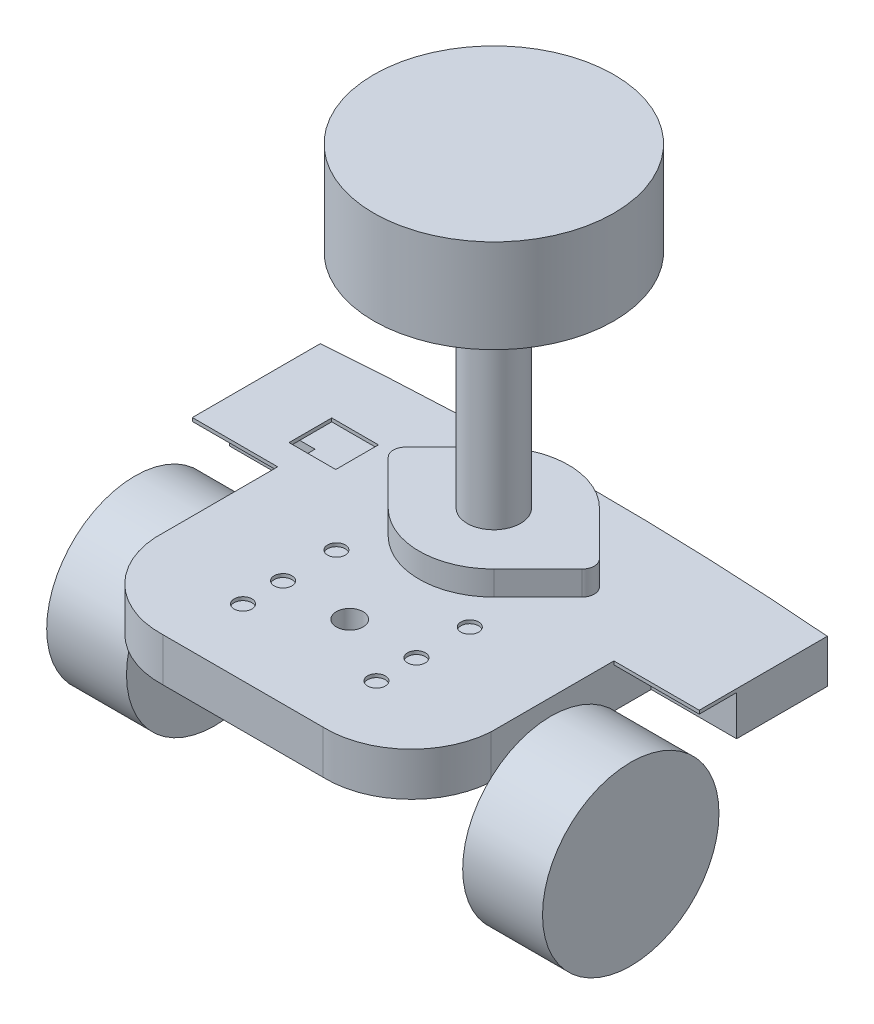
from build123d import *

# Parameters (mm, degrees)
EXTRUDE1_DEPTH     = 0.8128
SKETCH3_R          = 17.78
SKETCH3_R_2        = 1.651
EXTRUDE2_DEPTH     = 1.8128
SKETCH4_W          = 11.1125
SKETCH4_H          = 10.16
CUT_EXTRUDE1_DEPTH = 1.8128
SKETCH5_R          = 2.1082
EXTRUDE3_DEPTH     = 1.8128
EXTRUDE5_DEPTH     = 0.8128
EXTRUDE6_DEPTH     = 9.525
SKETCH8_R          = 2.918849546
SKETCH8_R_2        = 17.78
EXTRUDE7_DEPTH     = 6.604
SKETCH9_R          = 21
EXTRUDE8_DEPTH     = 19
SKETCH10_R         = 6.35
EXTRUDE9_DEPTH     = 52.832
SKETCH11_R         = 28.575
EXTRUDE10_DEPTH    = 22.225
SKETCH12_R         = 3.175
EXTRUDE11_DEPTH    = 46.892


with BuildPart() as part:
    # Sketch1 → Extrude1 (new body)
    with BuildSketch(Plane(origin=(0, 0, 0), x_dir=(1, 0, 0), z_dir=(0, 1, 0))):
        with BuildLine():
            Line((19.05, 0), (-19.05, 0))
            ThreePointArc((-19.05, 0), (-33.392740352, 5.273235613), (-40.005, 19.05))
            Line((-40.005, 19.05), (-40.005, 48.26))
            Line((-40.005, 48.26), (-60.325, 48.26))
            Line((-60.325, 48.26), (-60.325, 78.74))
            Line((-60.325, 78.74), (60.325, 78.74))
            Line((60.325, 78.74), (60.325, 48.26))
            Line((60.325, 48.26), (40.005, 48.26))
            Line((40.005, 48.26), (40.005, 19.05))
            ThreePointArc((40.005, 19.05), (33.392740352, 5.273235613), (19.05, 0))
        make_face()
    extrude(amount=EXTRUDE1_DEPTH)

    # Sketch3 → Extrude2 (cut, through all)
    with BuildSketch(Plane(origin=(0, 0.8128, 0), x_dir=(-1, 0, 0), z_dir=(0, 1, 0))):
        with Locations(Location((0, -59.69, 0), (0, 0, 90))):  # turned: the seam where the file's is
            Circle(SKETCH3_R)
        with Locations(Location((21, -59.69, 0), (0, 0, 90))):  # turned: the seam where the file's is
            Circle(SKETCH3_R_2)
        with Locations(Location((-21, -59.69, 0), (0, 0, 270))):  # turned: the seam where the file's is
            Circle(SKETCH3_R_2)
    extrude(amount=-EXTRUDE2_DEPTH, mode=Mode.SUBTRACT)

    # Sketch4 → Cut-Extrude1 (cut, through all)
    with BuildSketch(Plane(origin=(0, 0.8128, 0), x_dir=(-1, 0, 0), z_dir=(0, 1, 0))):
        with Locations((38.1, -59.69)):
            Rectangle(SKETCH4_W, SKETCH4_H)
    extrude(amount=-CUT_EXTRUDE1_DEPTH, mode=Mode.SUBTRACT)

    # Sketch5 → Extrude3 (cut, through all)
    with BuildSketch(Plane(origin=(0, 0.8128, 0), x_dir=(-1, 0, 0), z_dir=(0, 1, 0))):
        with Locations(Location((15.875, -38.1, 0), (0, 0, 90))):  # turned: the seam where the file's is
            Circle(SKETCH5_R)
        with Locations(Location((15.875, -25.4, 0), (0, 0, 90))):  # turned: the seam where the file's is
            Circle(SKETCH5_R)
        with Locations(Location((15.875, -15.875, 0), (0, 0, 90))):  # turned: the seam where the file's is
            Circle(SKETCH5_R)
        with Locations(Location((-15.875, -15.875, 0), (0, 0, 270))):  # turned: the seam where the file's is
            Circle(SKETCH5_R)
        with Locations(Location((-15.875, -25.4, 0), (0, 0, 270))):  # turned: the seam where the file's is
            Circle(SKETCH5_R)
        with Locations(Location((-15.875, -38.1, 0), (0, 0, 270))):  # turned: the seam where the file's is
            Circle(SKETCH5_R)
    extrude(amount=-EXTRUDE3_DEPTH, mode=Mode.SUBTRACT)

    # Sketch6 → Extrude5 (add, through all)
    with BuildSketch(Plane(origin=(0, 0.8128, 0), x_dir=(1, 0, 0), z_dir=(0, 1, 0))):
        with BuildLine():
            Line((-60.325, 78.74), (60.325, 78.74))
            ThreePointArc((60.325, 78.74), (0, 81.131617756), (-60.325, 78.74))
        make_face()
    extrude(amount=-EXTRUDE5_DEPTH)

    # Sketch7 → Extrude6 (add)
    with BuildSketch(Plane.XZ):
        with BuildLine():
            Line((-60.325, -78.74), (-60.325, -57.15))
            Line((-60.325, -57.15), (-40.005, -57.15))
            Line((-40.005, -57.15), (-40.005, -19.05))
            ThreePointArc((-40.005, -19.05), (-33.392740352, -5.273235613), (-19.05, 0))
            Line((-19.05, 0), (19.05, 0))
            ThreePointArc((19.05, 0), (33.392740352, -5.273235613), (40.005, -19.05))
            Line((40.005, -19.05), (40.005, -57.15))
            Line((40.005, -57.15), (60.325, -57.15))
            Line((60.325, -57.15), (60.325, -78.74))
            ThreePointArc((60.325, -78.74), (0, -81.131617756), (-60.325, -78.74))
        make_face()
    extrude(amount=EXTRUDE6_DEPTH)

    # Sketch8 → Extrude7 (add)
    with BuildSketch(Plane(origin=(0, 0, 0), x_dir=(1, 0, 0), z_dir=(0, 1, 0))):
        with BuildLine():
            Line((-12.582440718, 72.252268329), (-23.065593441, 61.752281845))
            ThreePointArc((-23.065593441, 61.752281845), (-19.884086429, 62.387113192), (-18.081150454, 59.69))
            ThreePointArc((-18.081150454, 59.69), (-19.884086429, 56.992886808), (-23.065593441, 57.627718155))
            Line((-23.065593441, 57.627718155), (-12.582440718, 47.127731671))
            ThreePointArc((-12.582440718, 47.127731671), (-17.78, 59.69), (-12.582440718, 72.252268329))
        make_face()
        with Locations((-21, 59.69)):
            Circle(SKETCH8_R)
        with Locations((0, 59.69)):
            Circle(SKETCH8_R_2)
        with BuildLine():
            Line((23.065593441, 61.752281845), (12.582440718, 72.252268329))
            ThreePointArc((12.582440718, 72.252268329), (16.429306071, 66.487521755), (17.78, 59.69))
            ThreePointArc((17.78, 59.69), (16.429306071, 52.892478245), (12.582440718, 47.127731671))
            Line((12.582440718, 47.127731671), (23.065593441, 57.627718155))
            ThreePointArc((23.065593441, 57.627718155), (18.081150454, 59.69), (23.065593441, 61.752281845))
        make_face()
        with Locations((21, 59.69)):
            Circle(SKETCH8_R)
    extrude(amount=EXTRUDE7_DEPTH)

    # Sketch10 → Extrude9 (add)
    with BuildSketch(Plane(origin=(0, 6.604, 0), x_dir=(-1, 0, 0), z_dir=(0, 1, 0))):
        with Locations(Location((0, -59.69, 0), (0, 0, 90))):  # turned: the seam where the file's is
            Circle(SKETCH10_R)
    extrude(amount=EXTRUDE9_DEPTH)

    # Sketch12 → Extrude11 (cut, through all)
    with BuildSketch(Plane(origin=(0, 0.8128, 0), x_dir=(-1, 0, 0), z_dir=(0, 1, 0))):
        with Locations(Location((0, -25.4, 0), (0, 0, 90))):  # turned: the seam where the file's is
            Circle(SKETCH12_R)
    extrude(amount=-EXTRUDE11_DEPTH, mode=Mode.SUBTRACT)


with BuildPart() as body_2:
    # Sketch9 → Extrude8 (new body)
    with BuildSketch(Plane(origin=(40.005, 0, 0), x_dir=(0, 0, -1), z_dir=(1, 0, 0))):
        with Locations((33.274, -24.0792)):
            Circle(SKETCH9_R)
    extrude(amount=EXTRUDE8_DEPTH)


with BuildPart() as body_3:
    # Mirror3: mirrored copy
    add(body_2.part.mirror(Plane(origin=(0, 0, 0), x_dir=(0, 0, 1), z_dir=(1, 0, 0))))


with BuildPart() as body_4:
    # Sketch11 → Extrude10 (new body)
    with BuildSketch(Plane(origin=(0, 59.436, 0), x_dir=(-1, 0, 0), z_dir=(0, 1, 0))):
        with Locations(Location((0, -59.69, 0), (0, 0, 90))):  # turned: the seam where the file's is
            Circle(SKETCH11_R)
    extrude(amount=EXTRUDE10_DEPTH)


solid = Compound([part.part, body_2.part, body_3.part, body_4.part])
